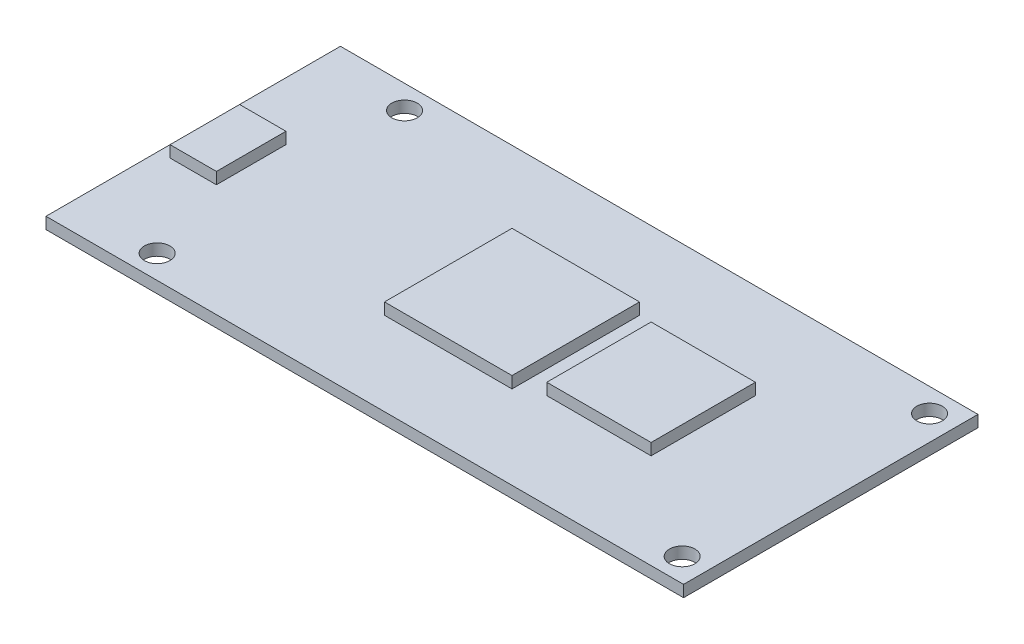
from build123d import *

# Parameters (mm, degrees)
SKETCH_1_W      = 55
SKETCH_1_H      = 25.4
SKETCH_1_R      = 1.1
SKETCH_1_W_2    = 4
SKETCH_1_H_2    = 6
SKETCH_1_W_3    = 11
SKETCH_1_H_3    = 11
SKETCH_1_W_4    = 9
SKETCH_1_H_4    = 9
EXTRUDE_1_DEPTH = 1
SKETCH_1_3_W    = 11
SKETCH_1_3_H    = 11
SKETCH_1_3_W_2  = 9
SKETCH_1_3_H_2  = 9
SKETCH_1_3_W_3  = 4
SKETCH_1_3_H_3  = 6
EXTRUDE_2_DEPTH = 2


with BuildPart() as part:
    # 草图1 → 凸台-拉伸1 (new body)
    with BuildSketch(Plane(origin=(0, 0, 0), x_dir=(1, 0, 0), z_dir=(0, 1, 0))):
        Rectangle(SKETCH_1_W, SKETCH_1_H)
        with Locations((-19.94, -10.67)):
            Circle(SKETCH_1_R, mode=Mode.SUBTRACT)
        with Locations((-24.5, 0)):
            Rectangle(SKETCH_1_W_2, SKETCH_1_H_2, mode=Mode.SUBTRACT)
        with Locations((25.35, -10.67)):
            Circle(SKETCH_1_R, mode=Mode.SUBTRACT)
        Rectangle(SKETCH_1_W_3, SKETCH_1_H_3, mode=Mode.SUBTRACT)
        with Locations((12, 0)):
            Rectangle(SKETCH_1_W_4, SKETCH_1_H_4, mode=Mode.SUBTRACT)
        with Locations((-19.94, 10.67)):
            Circle(SKETCH_1_R, mode=Mode.SUBTRACT)
        with Locations((25.35, 10.67)):
            Circle(SKETCH_1_R, mode=Mode.SUBTRACT)
    extrude(amount=EXTRUDE_1_DEPTH)

    # 草图1<3> → 凸台-拉伸2 (add)
    with BuildSketch(Plane(origin=(0, 0, 0), x_dir=(1, 0, 0), z_dir=(0, 1, 0))):
        Rectangle(SKETCH_1_3_W, SKETCH_1_3_H)
        with Locations((12, 0)):
            Rectangle(SKETCH_1_3_W_2, SKETCH_1_3_H_2)
        with Locations((-24.5, 0)):
            Rectangle(SKETCH_1_3_W_3, SKETCH_1_3_H_3)
    extrude(amount=EXTRUDE_2_DEPTH)


solid = part.part
